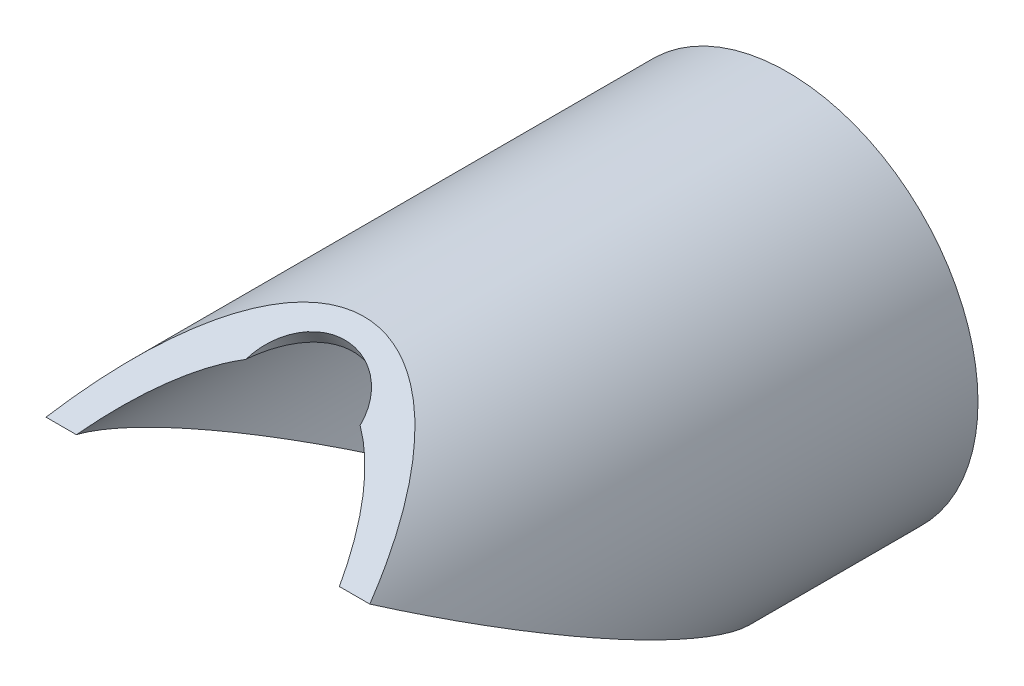
from build123d import *

# Parameters (mm, degrees)
BOSS_EXTRUDE1_DEPTH      = 203.2
BOSS_EXTRUDE1_DEPTH_BACK = 177.8
SKETCH1_R                = 83.4771
SKETCH1_R_2              = 72.5043
SKETCH8_W                = 2032
SKETCH8_H                = 2032
CUT_EXTRUDE10_DEPTH      = 304.8
SKETCH17_W               = 203.2
SKETCH17_H               = 508
CUT_EXTRUDE14_DEPTH      = 152.4
SKETCH18_R               = 25.4
CUT_EXTRUDE15_DEPTH      = 276.539452217


with BuildPart() as part:
    # Sketch1 → Boss-Extrude1 (new, two sides: drawn at the far end of the back side and taken through both)
    with BuildSketch(Plane.XY.offset(-BOSS_EXTRUDE1_DEPTH_BACK)):
        Circle(SKETCH1_R)
        Circle(SKETCH1_R_2, mode=Mode.SUBTRACT)
    extrude(amount=BOSS_EXTRUDE1_DEPTH + BOSS_EXTRUDE1_DEPTH_BACK)

    # Sketch8 → Cut-Extrude10 (cut)
    with BuildSketch(Plane(origin=(0, 0, 0), x_dir=(-1, 0, 0), z_dir=(0, 0.866025403784438, -0.5000000000000009))):
        Rectangle(SKETCH8_W, SKETCH8_H)
    extrude(amount=-CUT_EXTRUDE10_DEPTH, mode=Mode.SUBTRACT)

    # Sketch17 → Cut-Extrude14 (cut)
    with BuildSketch(Plane(origin=(0, 65.991135768, 38.1), x_dir=(-1, 0, 0), z_dir=(0, 0.866025403784438, 0.5000000000000009))):
        Rectangle(SKETCH17_W, SKETCH17_H)
    extrude(amount=CUT_EXTRUDE14_DEPTH, mode=Mode.SUBTRACT)

    # Sketch18 → Cut-Extrude15 (cut, through all)
    with BuildSketch(Plane(origin=(0, 65.991135768, 38.1), x_dir=(1, 0, 0), z_dir=(0, 0.8660254037844382, 0.500000000000001))):
        Circle(SKETCH18_R)
    extrude(amount=-CUT_EXTRUDE15_DEPTH, mode=Mode.SUBTRACT)


solid = part.part
